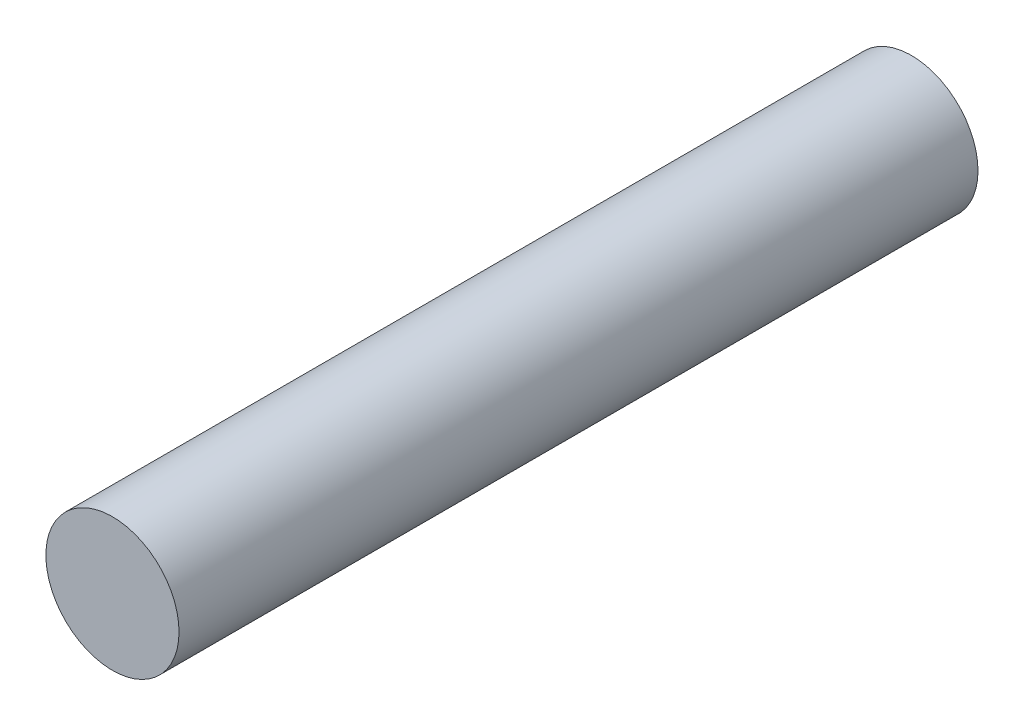
from build123d import *

# Parameters (mm, degrees)
SKETCH1_R           = 4.7625
BOSS_EXTRUDE1_DEPTH = 57.15


with BuildPart() as part:
    # Sketch1 → Boss-Extrude1 (new body)
    with BuildSketch(Plane.XY):
        Circle(SKETCH1_R)
    extrude(amount=BOSS_EXTRUDE1_DEPTH)


solid = part.part
